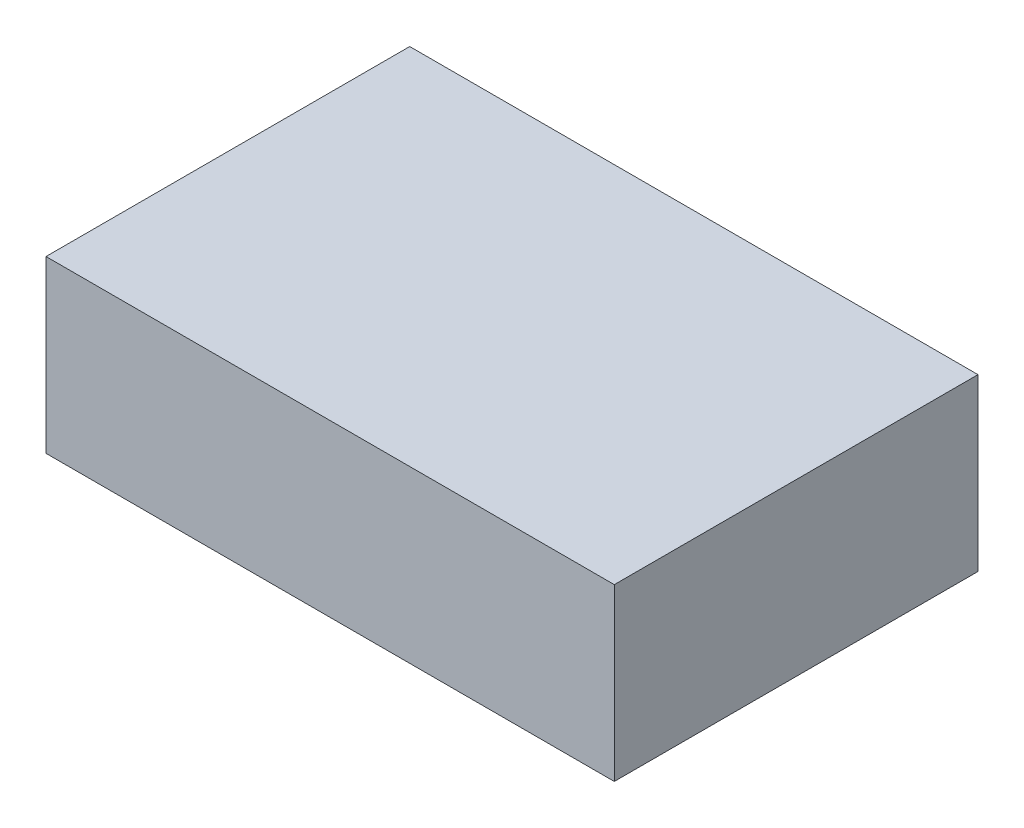
from build123d import *

# Parameters (mm, degrees)
SKETCH_1_W      = 50
SKETCH_1_H      = 32
EXTRUDE_1_DEPTH = 15


with BuildPart() as part:
    # 草图1 → 凸台-拉伸1 (new body)
    with BuildSketch(Plane(origin=(0, 0, 0), x_dir=(1, 0, 0), z_dir=(0, 1, 0))):
        with Locations((25, 16)):
            Rectangle(SKETCH_1_W, SKETCH_1_H)
    extrude(amount=EXTRUDE_1_DEPTH)


solid = part.part
